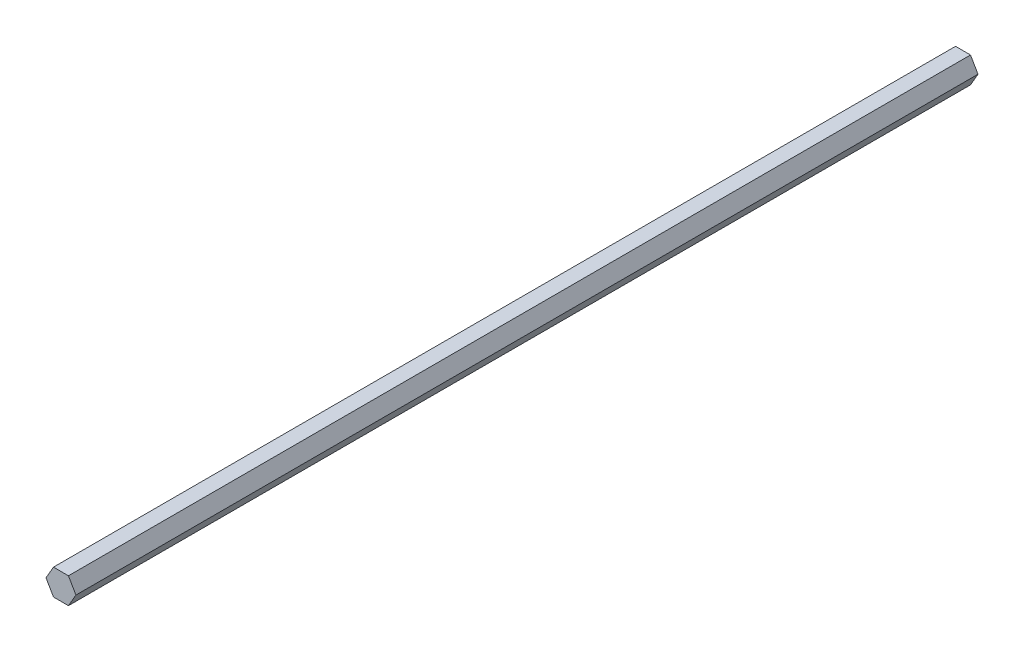
from build123d import *

# Parameters (mm, degrees)
BOSS_EXTRUDE1_DEPTH = 441.96


with BuildPart() as part:
    # Sketch1 → Boss-Extrude1 (new body)
    with BuildSketch(Plane.XY):
        Polygon((7.332348419, 0), (3.666174209, 6.35), (-3.666174209, 6.35), (-7.332348419, 0), (-3.666174209, -6.35), (3.666174209, -6.35), align=None)
    extrude(amount=BOSS_EXTRUDE1_DEPTH)


solid = part.part
